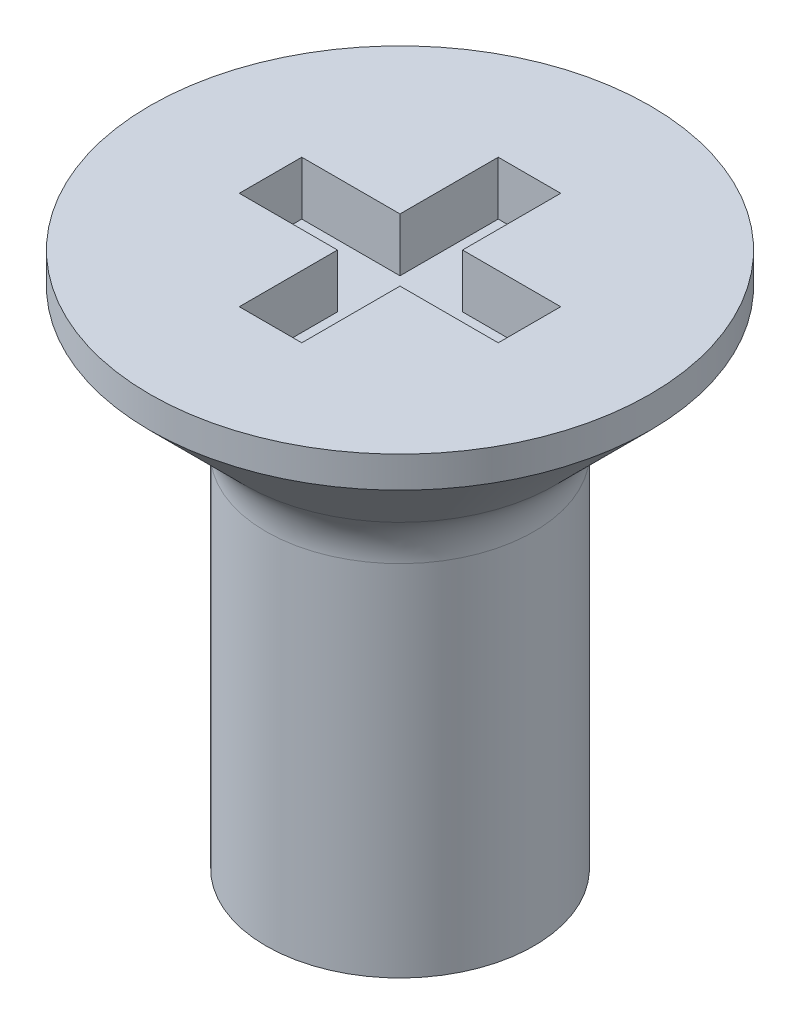
from build123d import *

# Parameters (mm, degrees)
FILLET1_R          = 0.8
SKETCH2_W          = 1.1
SKETCH2_H          = 0.7
SKETCH2_W_2        = 0.7
SKETCH2_H_2        = 1.1
CUT_EXTRUDE1_DEPTH = 0.6


with BuildPart() as part:
    # Sketch1 → Revolve1 (revolve)
    with BuildSketch(Plane.XY):
        Polygon((0, 0), (0, 6), (2.8, 6), (2.8, 5.65), (1.5, 4.35), (1.5, 0), align=None)
    revolve(axis=Axis((0, 0, 0), (0, 1, 0)))

    # Fillet1
    fillet1_edges = [part.edges().sort_by_distance(p)[0] for p in [
        (-1.5, 4.35, 0),
    ]]
    fillet(fillet1_edges, radius=FILLET1_R)

    # Sketch2 → Cut-Extrude1 (cut)
    with BuildSketch(Plane(origin=(0, 6, 0), x_dir=(1, 0, 0), z_dir=(0, 1, 0))):
        with Locations((-0.9, 0)):
            Rectangle(SKETCH2_W, SKETCH2_H)
        with Locations((0, 0.9)):
            Rectangle(SKETCH2_W_2, SKETCH2_H_2)
        Rectangle(SKETCH2_W_2, SKETCH2_H)
        with Locations((0.9, 0)):
            Rectangle(SKETCH2_W, SKETCH2_H)
        with Locations((0, -0.9)):
            Rectangle(SKETCH2_W_2, SKETCH2_H_2)
    extrude(amount=-CUT_EXTRUDE1_DEPTH, mode=Mode.SUBTRACT)


solid = part.part
